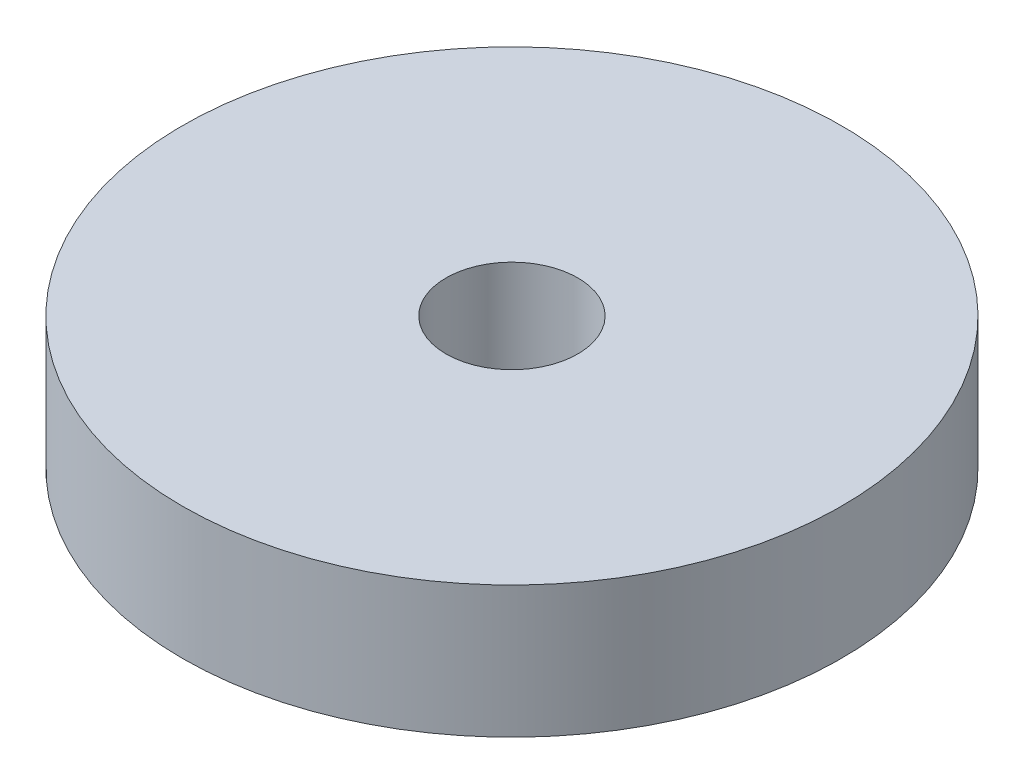
from build123d import *

# Parameters (mm, degrees)
SKETCH1_R           = 7.5
SKETCH1_R_2         = 1.5
BOSS_EXTRUDE1_DEPTH = 3


with BuildPart() as part:
    # Sketch1 → Boss-Extrude1 (new body)
    with BuildSketch(Plane(origin=(0, 0, 0), x_dir=(1, 0, 0), z_dir=(0, 1, 0))):
        Circle(SKETCH1_R)
        Circle(SKETCH1_R_2, mode=Mode.SUBTRACT)
    extrude(amount=BOSS_EXTRUDE1_DEPTH)


solid = part.part
